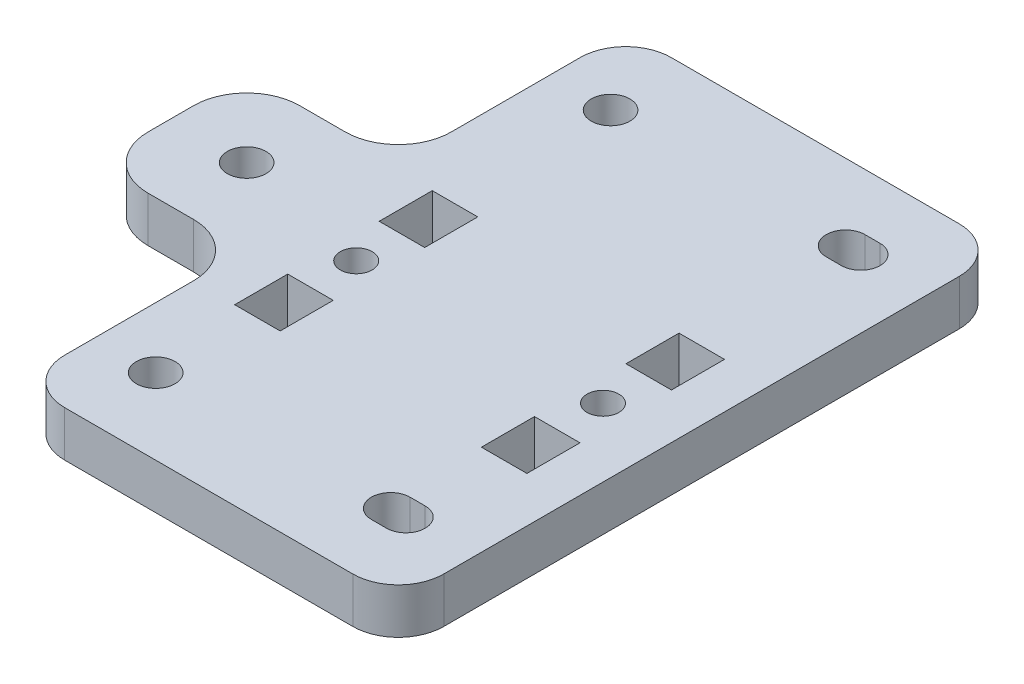
from build123d import *

# Parameters (mm, degrees)
SKETCH_1_R           = 2.55
EXTRUDE_1_DEPTH      = 6
SKETCH_2_R           = 2.55
CUT_EXTRUDE_1_DEPTH  = 7
SKETCH_3_R           = 2.1
SKETCH_3_W           = 7
SKETCH_3_H           = 6
CUT_EXTRUDE_11_DEPTH = 7
SKETCH_31_R          = 2.1
SKETCH_31_W          = 7
SKETCH_31_H          = 6
CUT_EXTRUDE_12_DEPTH = 7


with BuildPart() as part:
    # Эскиз1 → Бобышка-Вытянуть1 (new body)
    with BuildSketch(Plane(origin=(0, 0, 0), x_dir=(1, 0, 0), z_dir=(0, 1, 0))):
        with BuildLine():
            Line((-32, -10), (-38, -10))
            ThreePointArc((-38, -10), (-42.949747468, -7.949747468), (-45, -3))
            Line((-45, -3), (-45, 3))
            ThreePointArc((-45, 3), (-42.949747468, 7.949747468), (-38, 10))
            Line((-38, 10), (-32, 10))
            ThreePointArc((-32, 10), (-27.050252532, 12.050252532), (-25, 17))
            Line((-25, 17), (-25, 34))
            ThreePointArc((-25, 34), (-23.242640687, 38.242640687), (-19, 40))
            Line((-19, 40), (19, 40))
            ThreePointArc((19, 40), (23.242640687, 38.242640687), (25, 34))
            Line((25, 34), (25, -34))
            ThreePointArc((25, -34), (23.242640687, -38.242640687), (19, -40))
            Line((19, -40), (-19, -40))
            ThreePointArc((-19, -40), (-23.242640687, -38.242640687), (-25, -34))
            Line((-25, -34), (-25, -17))
            ThreePointArc((-25, -17), (-27.050252532, -12.050252532), (-32, -10))
        make_face()
        with Locations((-35, 0)):
            Circle(SKETCH_1_R, mode=Mode.SUBTRACT)
    extrude(amount=EXTRUDE_1_DEPTH)

    # Эскиз2 → Вырез-Вытянуть1 (cut, through all)
    with BuildSketch(Plane.XZ):
        with Locations((-17, -30)):
            Circle(SKETCH_2_R)
        with Locations((-17, 30)):
            Circle(SKETCH_2_R)
        with BuildLine():
            Line((16, -32.55), (14, -32.55))
            ThreePointArc((14, -32.55), (11.45, -30), (14, -27.45))
            Line((14, -27.45), (16, -27.45))
            ThreePointArc((16, -27.45), (18.55, -30), (16, -32.55))
        make_face()
        with BuildLine():
            Line((16, 32.55), (14, 32.55))
            ThreePointArc((14, 32.55), (11.45, 30), (14, 27.45))
            Line((14, 27.45), (16, 27.45))
            ThreePointArc((16, 27.45), (18.55, 30), (16, 32.55))
        make_face()
    extrude(amount=-CUT_EXTRUDE_1_DEPTH, mode=Mode.SUBTRACT)

    # Эскиз3 → Вырез-Вытянуть11 (cut, through all)
    with BuildSketch(Plane(origin=(-31, 0, 4), x_dir=(0, 0, -1), z_dir=(0, -1, 0))):
        with Locations((0, 47)):
            Circle(SKETCH_3_R)
        with Locations((9.531849908, 47)):
            Rectangle(SKETCH_3_W, SKETCH_3_H)
        with Locations((-9.531849908, 47)):
            Rectangle(SKETCH_3_W, SKETCH_3_H)
    extrude(amount=-CUT_EXTRUDE_11_DEPTH, mode=Mode.SUBTRACT)

    # Эскиз31 → Вырез-Вытянуть12 (cut, through all)
    with BuildSketch(Plane(origin=(30.45, 0, 4), x_dir=(0, 0, 1), z_dir=(0, -1, 0))):
        with Locations((0, 47)):
            Circle(SKETCH_31_R)
        with Locations((9.531849908, 47)):
            Rectangle(SKETCH_31_W, SKETCH_31_H)
        with Locations((-9.531849908, 47)):
            Rectangle(SKETCH_31_W, SKETCH_31_H)
    extrude(amount=-CUT_EXTRUDE_12_DEPTH, mode=Mode.SUBTRACT)


solid = part.part
